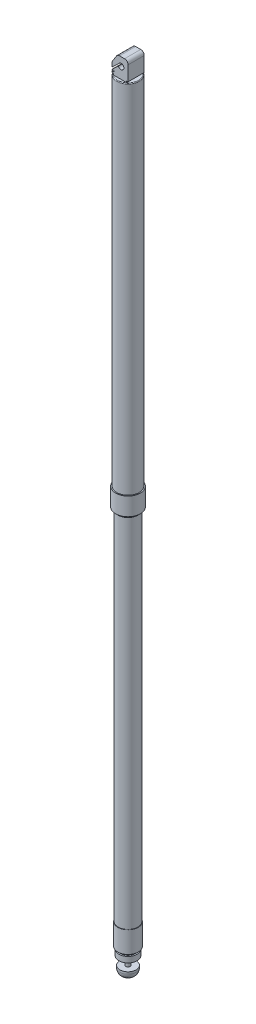
from build123d import *

# Parameters (mm, degrees)
BOSS_EXTRUDE1_DEPTH = 11.5
FILLET1_R           = 5
SKETCH2_R           = 16
BOSS_EXTRUDE2_DEPTH = 508
FILLET2_R           = 1
SKETCH4_R           = 17.5
BOSS_EXTRUDE3_DEPTH = 29
CHAMFER1_SIZE       = 3.5
SKETCH5_R           = 14
BOSS_EXTRUDE4_DEPTH = 508
SKETCH6_R           = 14.5
BOSS_EXTRUDE5_DEPTH = 34
CHAMFER2_SIZE       = 3.5
SKETCH7_R           = 13
BOSS_EXTRUDE6_DEPTH = 8
SKETCH8_R           = 3.175
BOSS_EXTRUDE7_DEPTH = 12
SKETCH9_R           = 11.5
BOSS_EXTRUDE8_DEPTH = 12
FILLET3_R           = 9


with BuildPart() as part:
    # Sketch1 → Boss-Extrude1 (new, symmetric)
    with BuildSketch(Plane.XY):
        with BuildLine():
            Line((-33.008488745, -30.177022886), (-48.008488745, -30.177022886))
            Line((-48.008488745, -30.177022886), (-56.008488745, -42.865600426))
            Line((-56.008488745, -42.865600426), (-56.008488745, -49.440306382))
            Line((-56.008488745, -49.440306382), (-46.767158149, -40.808664634))
            ThreePointArc((-46.767158149, -40.808664634), (-39.008488745, -42.177022886), (-46.767158149, -43.545381137))
            Line((-46.767158149, -43.545381137), (-56.008488745, -52.177022886))
            Line((-56.008488745, -52.177022886), (-53.008488745, -52.177022886))
            Line((-53.008488745, -52.177022886), (-53.008488745, -54.177022886))
            Line((-53.008488745, -54.177022886), (-56.008488745, -54.177022886))
            Line((-56.008488745, -54.177022886), (-56.008488745, -56.177022886))
            Line((-56.008488745, -56.177022886), (-54.008488745, -56.177022886))
            Line((-54.008488745, -56.177022886), (-54.008488745, -58.177022886))
            Line((-54.008488745, -58.177022886), (-35.008488745, -58.177022886))
            Line((-35.008488745, -58.177022886), (-35.008488745, -56.177022886))
            Line((-35.008488745, -56.177022886), (-33.008488745, -56.177022886))
            Line((-33.008488745, -56.177022886), (-33.008488745, -30.177022886))
        make_face()
    extrude(amount=BOSS_EXTRUDE1_DEPTH, both=True)

    # Fillet1
    fillet1_edges = [part.edges().sort_by_distance(p)[0] for p in [
        (-56.008488745, -42.865600426, 0),
        (-48.008488745, -30.177022886, 0),
        (-33.008488745, -30.177022886, 0),
    ]]
    fillet(fillet1_edges, radius=FILLET1_R)

    # Sketch2 → Boss-Extrude2 (add)
    with BuildSketch(Plane(origin=(0, -58.177022886, 0), x_dir=(-1, 0, 0), z_dir=(0, -1, 0))):
        with Locations((44.508488745, -0.100800937)):
            Circle(SKETCH2_R)
    extrude(amount=BOSS_EXTRUDE2_DEPTH)

    # Fillet2
    fillet2_edges = [part.edges().sort_by_distance(p)[0] for p in [
        (-28.508488745, -58.177022886, 0.100800937),
    ]]
    fillet(fillet2_edges, radius=FILLET2_R)

    # Sketch4 → Boss-Extrude3 (add)
    with BuildSketch(Plane(origin=(0, -566.177022886, 0), x_dir=(-1, 0, 0), z_dir=(0, -1, 0))):
        with Locations((44.508488745, -0.100800937)):
            Circle(SKETCH4_R)
    extrude(amount=BOSS_EXTRUDE3_DEPTH)

    # Chamfer1
    chamfer1_edges = [part.edges().sort_by_distance(p)[0] for p in [
        (-27.008488745, -595.177022886, 0.100800937),
    ]]
    chamfer(chamfer1_edges, length=CHAMFER1_SIZE)

    # Sketch5 → Boss-Extrude4 (add)
    with BuildSketch(Plane(origin=(0, -595.177022886, 0), x_dir=(-1, 0, 0), z_dir=(0, -1, 0))):
        with Locations((44.508488745, -0.100800937)):
            Circle(SKETCH5_R)
    extrude(amount=BOSS_EXTRUDE4_DEPTH)

    # Sketch6 → Boss-Extrude5 (add)
    with BuildSketch(Plane.XZ.offset(1103.177022886)):
        with Locations((-44.508488745, 0.100800937)):
            Circle(SKETCH6_R)
    extrude(amount=BOSS_EXTRUDE5_DEPTH)

    # Chamfer2
    chamfer2_edges = [part.edges().sort_by_distance(p)[0] for p in [
        (-59.008488745, -1137.177022886, 0.100800937),
    ]]
    chamfer(chamfer2_edges, length=CHAMFER2_SIZE)

    # Sketch7 → Boss-Extrude6 (add)
    with BuildSketch(Plane.XZ.offset(1137.177022886)):
        with Locations((-44.508488745, 0.100800937)):
            Circle(SKETCH7_R)
    extrude(amount=BOSS_EXTRUDE6_DEPTH)

    # Sketch8 → Boss-Extrude7 (add)
    with BuildSketch(Plane.XZ.offset(1145.177022886)):
        with Locations((-44.508488745, 0.100800937)):
            Circle(SKETCH8_R)
    extrude(amount=BOSS_EXTRUDE7_DEPTH)

    # Sketch9 → Boss-Extrude8 (add)
    with BuildSketch(Plane(origin=(0, -1157.177022886, 0), x_dir=(-1, 0, 0), z_dir=(0, -1, 0))):
        with Locations((44.508488745, -0.100800937)):
            Circle(SKETCH9_R)
    extrude(amount=BOSS_EXTRUDE8_DEPTH)

    # Fillet3
    fillet3_edges = [part.edges().sort_by_distance(p)[0] for p in [
        (-33.008488745, -1169.177022886, 0.100800937),
    ]]
    fillet(fillet3_edges, radius=FILLET3_R)


solid = part.part
